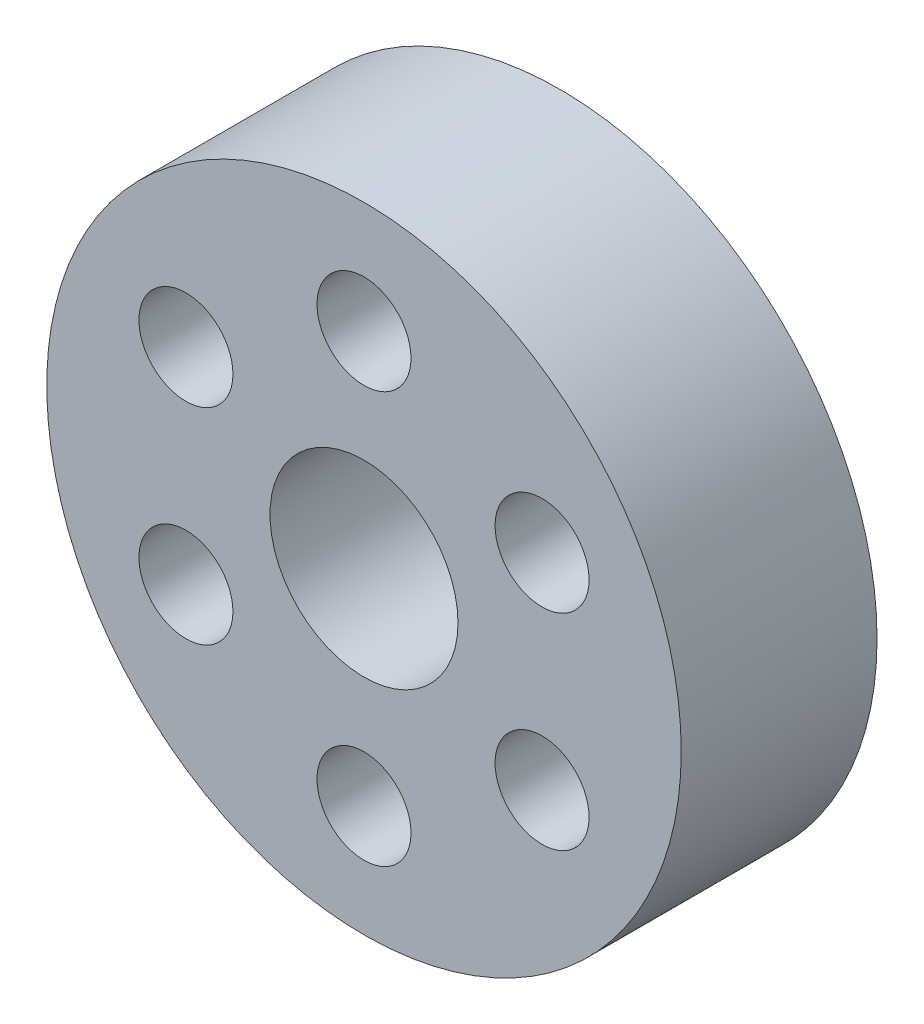
from build123d import *

# Parameters (mm, degrees)
SKETCH1_R           = 5.1435
SKETCH1_R_2         = 1.524
BOSS_EXTRUDE1_DEPTH = 3.175
SKETCH2_R           = 0.762
CUT_EXTRUDE1_DEPTH  = 3.175
CIRPATTERN1_COUNT   = 6


with BuildPart() as part:
    # Sketch1 → Boss-Extrude1 (new body)
    with BuildSketch(Plane.XY):
        Circle(SKETCH1_R)
        Circle(SKETCH1_R_2, mode=Mode.SUBTRACT)
    extrude(amount=BOSS_EXTRUDE1_DEPTH)

    # Sketch2 → Cut-Extrude1 (cut)
    with BuildSketch(Plane.XY.offset(3.175)):
        with Locations((0, 3.33375)):
            Circle(SKETCH2_R)
    cut_extrude1 = extrude(amount=-CUT_EXTRUDE1_DEPTH, mode=Mode.SUBTRACT)

    # CirPattern1: Cut-Extrude1 ×6 about axis
    cirpattern1_axis = Axis((0, 0, 0), (0, 0, 1))
    for i in range(1, CIRPATTERN1_COUNT):
        add(cut_extrude1.rotate(cirpattern1_axis, i * 360 / CIRPATTERN1_COUNT), mode=Mode.SUBTRACT)


solid = part.part
